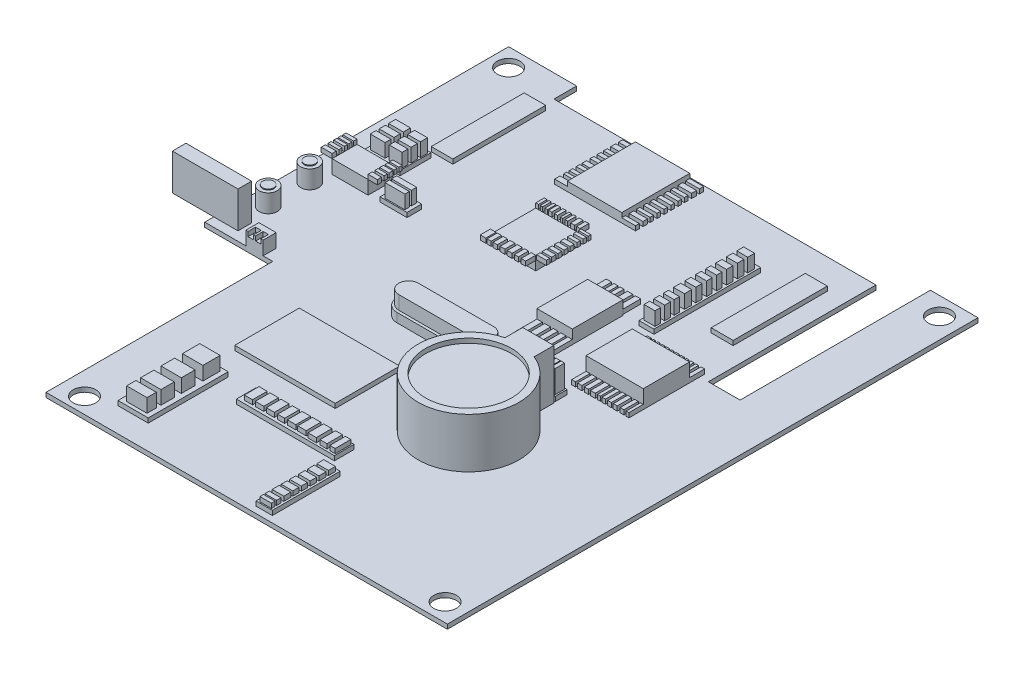
from build123d import *

# Parameters (mm, degrees)
BOSS_EXTRUDE1_DEPTH     = 1
SKETCH29_R              = 2.5
CUT_EXTRUDE1_DEPTH      = 1
SKETCH30_R              = 9.474583062
BOSS_EXTRUDE2_DEPTH     = 10
SKETCH32_R              = 11.129481628
SKETCH32_R_2            = 9.474583062
BOSS_EXTRUDE5_DEPTH     = 11
SKETCH33_W              = 6.859282088
SKETCH33_H              = 4.336444126
BOSS_EXTRUDE6_DEPTH     = 11
SKETCH94_W              = 6.467351118
SKETCH94_H              = 2.610316415
BOSS_EXTRUDE70_DEPTH    = 1
SKETCH95_W              = 0.898636231
SKETCH95_H              = 2.146154762
SKETCH95_W_2            = 0.803486512
SKETCH95_W_3            = 0.771769939
SKETCH95_W_4            = 0.78234213
SKETCH95_W_5            = 0.89863623
BOSS_EXTRUDE71_DEPTH    = 5
SKETCH96_W              = 12.624398434
SKETCH96_H              = 10.212996486
SKETCH96_W_2            = 7.801594538
SKETCH96_H_2            = 11.135003114
BOSS_EXTRUDE72_DEPTH    = 1
SKETCH97_W              = 0.854933858
SKETCH97_H              = 3.195934529
SKETCH97_W_2            = 0.973382942
SKETCH97_W_3            = 0.928109316
SKETCH97_W_4            = 1.063930191
SKETCH97_W_5            = 0.635991976
SKETCH97_W_6            = 0.769651627
SKETCH97_W_7            = 0.814925253
SKETCH97_W_8            = 0.882835691
SKETCH97_W_9            = 0.837562066
SKETCH97_W_10           = 0.60988367
SKETCH97_H_2            = 3.281548827
SKETCH97_W_11           = 0.486691471
SKETCH97_W_12           = 0.520646689
SKETCH97_W_13           = 0.689780349
SKETCH97_W_14           = 0.777801053
SKETCH97_W_15           = 0.598512769
SKETCH97_W_16           = 0.767490405
SKETCH97_W_17           = 0.67295067
SKETCH97_W_18           = 0.564415835
SKETCH97_W_19           = 0.651586297
SKETCH97_W_20           = 0.589205462
SKETCH97_W_21           = 0.803776824
BOSS_EXTRUDE73_DEPTH    = 1
SKETCH98_W              = 12.624398434
SKETCH98_H              = 10.197037506
BOSS_EXTRUDE74_DEPTH    = 3
SKETCH99_W              = 1.171777811
SKETCH99_H              = 4.8472176
SKETCH99_W_2            = 1.302225945
SKETCH99_W_3            = 1.035102674
SKETCH99_W_4            = 1.135273901
SKETCH99_W_5            = 0.986837632
SKETCH99_H_2            = 4.152195819
SKETCH99_W_6            = 0.901541038
SKETCH99_W_7            = 0.892546971
SKETCH99_W_8            = 1.202054718
SKETCH99_W_9            = 1.168664309
BOSS_EXTRUDE76_DEPTH    = 1
SKETCH100_W             = 7.801594538
SKETCH100_H             = 11.174835623
BOSS_EXTRUDE77_DEPTH    = 3
SKETCH101_W             = 4.843414572
SKETCH101_H             = 20.757491024
SKETCH101_W_2           = 3.286602746
SKETCH101_H_2           = 23.525156494
BOSS_EXTRUDE78_DEPTH    = 1
SKETCH102_W             = 2.415516683
SKETCH102_H             = 1.519437913
SKETCH102_H_2           = 1.44151802
SKETCH102_H_3           = 1.402558073
SKETCH102_H_4           = 1.168798395
SKETCH102_H_5           = 1.246718288
SKETCH102_H_6           = 1.363598127
SKETCH102_H_7           = 1.597357806
SKETCH102_H_8           = 1.168798394
SKETCH102_H_9           = 1.285678234
BOSS_EXTRUDE79_DEPTH    = 3
BOSS_EXTRUDE81_DEPTH    = 2
BOSS_EXTRUDE82_DEPTH    = 3
SKETCH109_W             = 22.146512199
SKETCH109_H             = 14.224182632
BOSS_EXTRUDE83_DEPTH    = 1
SKETCH110_W             = 6.661958954
SKETCH110_H             = 17.645188581
SKETCH110_W_2           = 21.606353365
SKETCH110_H_2           = 4.321270673
SKETCH110_W_3           = 3.601058894
SKETCH110_H_3           = 14.944394411
BOSS_EXTRUDE84_DEPTH    = 1
SKETCH111_W             = 4.495051817
SKETCH111_H             = 3.811022193
SKETCH111_H_2           = 3.029274051
SKETCH111_H_3           = 2.931555533
SKETCH111_H_4           = 2.052088873
BOSS_EXTRUDE85_DEPTH    = 3
SKETCH112_W             = 1.800095307
SKETCH112_H             = 3.236858559
SKETCH112_W_2           = 1.884972771
SKETCH112_W_3           = 1.772435211
SKETCH112_W_4           = 1.548527582
SKETCH112_W_5           = 1.856145182
SKETCH112_W_6           = 1.855853309
SKETCH112_W_7           = 1.827317594
SKETCH112_H_2           = 3.432631011
SKETCH112_W_8           = 1.548381646
SKETCH112_W_9           = 1.185151979
SKETCH112_W_10          = 2.560532791
SKETCH112_H_3           = 1.542958829
SKETCH112_H_4           = 1.543391648
SKETCH112_H_5           = 1.403004622
SKETCH112_H_6           = 1.348494525
SKETCH112_H_7           = 1.321023067
SKETCH112_H_8           = 1.54209319
SKETCH112_H_9           = 0.961730017
SKETCH112_H_10          = 0.794737171
BOSS_EXTRUDE86_DEPTH    = 1
SKETCH113_W             = 10
SKETCH113_H             = 10
SKETCH113_W_2           = 12
SKETCH113_H_2           = 15
BOSS_EXTRUDE87_DEPTH    = 2
SKETCH114_W             = 3.027436152
SKETCH114_H             = 0.924530577
SKETCH114_H_2           = 1.106308727
SKETCH114_H_3           = 0.804588165
SKETCH114_H_4           = 0.838112671
SKETCH114_H_5           = 0.838112672
SKETCH114_H_6           = 0.771063658
SKETCH114_H_7           = 1.005735206
SKETCH114_H_8           = 0.832239043
SKETCH114_W_2           = 2.793868574
SKETCH114_H_9           = 1.039259713
SKETCH114_H_10          = 0.670490137
SKETCH114_H_11          = 1.201008619
BOSS_EXTRUDE90_DEPTH    = 1
SKETCH115_W             = 1.218252667
SKETCH115_H             = 2.2340069
BOSS_EXTRUDE92_DEPTH    = 1
SKETCH115_W_2           = 0.904538566
BOSS_EXTRUDE92_2_DEPTH  = 1
SKETCH115_W_3           = 0.933717229
BOSS_EXTRUDE92_3_DEPTH  = 1
SKETCH115_W_4           = 1.050431882
BOSS_EXTRUDE92_4_DEPTH  = 1
SKETCH115_W_5           = 1.079610546
BOSS_EXTRUDE92_5_DEPTH  = 1
SKETCH115_W_6           = 0.875359903
BOSS_EXTRUDE92_6_DEPTH  = 1
SKETCH115_W_7           = 0.991044204
BOSS_EXTRUDE92_7_DEPTH  = 1
SKETCH115_W_8           = 2.132919208
SKETCH115_H_2           = 0.769606673
BOSS_EXTRUDE92_8_DEPTH  = 1
SKETCH115_H_3           = 0.945593409
BOSS_EXTRUDE92_9_DEPTH  = 1
SKETCH115_H_4           = 0.857604907
BOSS_EXTRUDE92_10_DEPTH = 1
SKETCH115_H_5           = 0.890627016
BOSS_EXTRUDE92_11_DEPTH = 1
SKETCH115_H_6           = 0.923595473
BOSS_EXTRUDE92_12_DEPTH = 1
SKETCH115_H_7           = 0.725614044
BOSS_EXTRUDE92_13_DEPTH = 1
SKETCH115_H_8           = 0.725623774
BOSS_EXTRUDE92_14_DEPTH = 1
SKETCH115_H_9           = 0.589147012
BOSS_EXTRUDE92_15_DEPTH = 1
SKETCH115_W_9           = 0.791437707
SKETCH115_H_10          = 1.896778749
BOSS_EXTRUDE92_16_DEPTH = 1
SKETCH115_W_10          = 0.902152651
BOSS_EXTRUDE92_17_DEPTH = 1
SKETCH115_W_11          = 0.61284124
BOSS_EXTRUDE92_18_DEPTH = 1
SKETCH115_W_12          = 0.525215942
BOSS_EXTRUDE92_19_DEPTH = 1
SKETCH115_W_13          = 0.704131469
BOSS_EXTRUDE92_20_DEPTH = 1
SKETCH115_W_14          = 0.706624959
BOSS_EXTRUDE92_21_DEPTH = 1
SKETCH115_W_15          = 0.572005981
BOSS_EXTRUDE92_22_DEPTH = 1
SKETCH115_W_16          = 0.510666695
BOSS_EXTRUDE92_23_DEPTH = 1
SKETCH115_W_17          = 0.603378895
BOSS_EXTRUDE92_24_DEPTH = 1
SKETCH116_W             = 4.749694189
SKETCH116_H             = 20.485451176
BOSS_EXTRUDE93_DEPTH    = 1
SKETCH117_W             = 7.945632429
SKETCH117_H             = 6.823502315
BOSS_EXTRUDE94_DEPTH    = 1
SKETCH118_W             = 3.270069498
SKETCH118_H             = 1.558773398
SKETCH118_W_2           = 2.842213247
SKETCH118_H_2           = 1.405995231
SKETCH118_H_3           = 1.283794323
BOSS_EXTRUDE95_DEPTH    = 3
SKETCH119_W             = 7.939308206
SKETCH119_H             = 5.475326854
BOSS_EXTRUDE96_DEPTH    = 3
SKETCH120_W             = 2.046149279
SKETCH120_H             = 0.734786807
BOSS_EXTRUDE97_DEPTH    = 1
SKETCH120_H_2           = 0.69351132
BOSS_EXTRUDE97_2_DEPTH  = 1
SKETCH120_H_3           = 0.842069262
BOSS_EXTRUDE97_3_DEPTH  = 1
SKETCH120_H_4           = 0.718287404
BOSS_EXTRUDE97_4_DEPTH  = 1
SKETCH120_H_5           = 0.928140606
BOSS_EXTRUDE97_5_DEPTH  = 1
SKETCH120_W_2           = 2.395983096
BOSS_EXTRUDE97_6_DEPTH  = 1
BOSS_EXTRUDE97_7_DEPTH  = 1
SKETCH120_H_6           = 0.666256695
BOSS_EXTRUDE97_8_DEPTH  = 1
BOSS_EXTRUDE97_9_DEPTH  = 1
BOSS_EXTRUDE97_10_DEPTH = 1
SKETCH121_W             = 5.943186366
SKETCH121_H             = 3.194636387
BOSS_EXTRUDE98_DEPTH    = 1
SKETCH122_W             = 4.383064798
SKETCH122_H             = 1.164264213
SKETCH122_H_2           = 0.990955742
BOSS_EXTRUDE99_DEPTH    = 3
SKETCH123_R             = 2
BOSS_EXTRUDE100_DEPTH   = 4
SKETCH125_R             = 1.241746015
SKETCH125_R_2           = 1.24572754
BOSS_EXTRUDE104_DEPTH   = 4.2
SKETCH126_W             = 3.798066901
SKETCH126_H             = 2.877820421
BOSS_EXTRUDE106_DEPTH   = 3
SKETCH128_W             = 1.251148543
SKETCH128_H             = 1.660086607
SKETCH128_W_2           = 1.13826296
CUT_EXTRUDE20_DEPTH     = 1
BOSS_EXTRUDE108_DEPTH   = 8
SKETCH131_W             = 5
SKETCH131_H             = 2
CUT_EXTRUDE22_DEPTH     = 1
SKETCH132_W             = 1.433328205
SKETCH132_H             = 7.5
CUT_EXTRUDE23_DEPTH     = 8
SKETCH133_W             = 1.5
SKETCH133_H             = 117
CUT_EXTRUDE24_DEPTH     = 2


with BuildPart() as part:
    # Sketch1 → Boss-Extrude1 (new body)
    with BuildSketch(Plane(origin=(0, 0, 0), x_dir=(1, 0, 0), z_dir=(0, 1, 0))):
        Polygon((93, 0), (105, 0), (105, -117), (15, -117), (15, -67), (0, -67), (0, 0), (15, 0), (15, -5), (86, -5), (86, -41.962014215), (93, -41.962014215), align=None)
    extrude(amount=BOSS_EXTRUDE1_DEPTH)

    # Sketch29 → Cut-Extrude1 (cut)
    with BuildSketch(Plane(origin=(0, 1, 0), x_dir=(1, 0, 0), z_dir=(0, 1, 0))):
        with Locations((99, -4)):
            Circle(SKETCH29_R)
        with Locations((4, -4)):
            Circle(SKETCH29_R)
        with Locations((20, -113.5)):
            Circle(SKETCH29_R)
        with Locations((99, -113)):
            Circle(SKETCH29_R)
    extrude(amount=-CUT_EXTRUDE1_DEPTH, mode=Mode.SUBTRACT)

    # Sketch30 → Boss-Extrude2 (add)
    with BuildSketch(Plane(origin=(0, 1, 0), x_dir=(1, 0, 0), z_dir=(0, 1, 0))):
        with Locations((68.930428836, -77.750419339)):
            Circle(SKETCH30_R)
    extrude(amount=BOSS_EXTRUDE2_DEPTH)

    # Sketch32 → Boss-Extrude5 (add)
    with BuildSketch(Plane(origin=(0, 1, 0), x_dir=(1, 0, 0), z_dir=(0, 1, 0))):
        with Locations((68.930428836, -77.750419339)):
            Circle(SKETCH32_R)
        with Locations((68.930428836, -77.750419339)):
            Circle(SKETCH32_R_2, mode=Mode.SUBTRACT)
    extrude(amount=BOSS_EXTRUDE5_DEPTH)

    # Sketch33 → Boss-Extrude6 (add)
    with BuildSketch(Plane(origin=(0, 1, 0), x_dir=(1, 0, 0), z_dir=(0, 1, 0))):
        with Locations((69.603565091, -65.236542161)):
            Rectangle(SKETCH33_W, SKETCH33_H)
    extrude(amount=BOSS_EXTRUDE6_DEPTH)

    # Sketch94 → Boss-Extrude70 (add)
    with BuildSketch(Plane(origin=(0, 1, 0), x_dir=(1, 0, 0), z_dir=(0, 1, 0))):
        with Locations((69.673344387, -61.312235302)):
            Rectangle(SKETCH94_W, SKETCH94_H)
    extrude(amount=BOSS_EXTRUDE70_DEPTH)

    # Sketch95 → Boss-Extrude71 (add)
    with BuildSketch(Plane(origin=(0, 2, 0), x_dir=(1, 0, 0), z_dir=(0, 1, 0))):
        with Locations((67.15008351, -61.310670018)):
            Rectangle(SKETCH95_W, SKETCH95_H)
        with Locations((68.212588701, -61.310670018)):
            Rectangle(SKETCH95_W_2, SKETCH95_H)
        with Locations((69.179944173, -61.310670018)):
            Rectangle(SKETCH95_W_3, SKETCH95_H)
        with Locations((70.094438689, -61.310670018)):
            Rectangle(SKETCH95_W_4, SKETCH95_H)
        with Locations((71.178088261, -61.310670018)):
            Rectangle(SKETCH95_W_5, SKETCH95_H)
        with Locations((72.203590783, -61.310670018)):
            Rectangle(SKETCH95_W_3, SKETCH95_H)
    extrude(amount=BOSS_EXTRUDE71_DEPTH)

    # Sketch96 → Boss-Extrude72 (add)
    with BuildSketch(Plane(origin=(0, 1, 0), x_dir=(1, 0, 0), z_dir=(0, 1, 0))):
        with Locations((77.833652458, -49.309656676)):
            Rectangle(SKETCH96_W, SKETCH96_H)
        with Locations((60.031832194, -44.309543813)):
            Rectangle(SKETCH96_W_2, SKETCH96_H_2)
    extrude(amount=BOSS_EXTRUDE72_DEPTH)

    # Sketch97 → Boss-Extrude73 (add)
    with BuildSketch(Plane(origin=(0, 1, 0), x_dir=(1, 0, 0), z_dir=(0, 1, 0))):
        with Locations((71.94892017, -56.014122184)):
            Rectangle(SKETCH97_W, SKETCH97_H)
        with Locations((73.292810312, -56.014122184)):
            Rectangle(SKETCH97_W_2, SKETCH97_H)
        with Locations((74.76420313, -56.014122184)):
            Rectangle(SKETCH97_W_3, SKETCH97_H)
        with Locations((76.190322323, -56.014122184)):
            Rectangle(SKETCH97_W_4, SKETCH97_H)
        with Locations((77.51565647, -56.014122184)):
            Rectangle(SKETCH97_W_5, SKETCH97_H)
        with Locations((78.601142863, -56.014122184)):
            Rectangle(SKETCH97_W_6, SKETCH97_H)
        with Locations((79.868804368, -56.014122184)):
            Rectangle(SKETCH97_W_7, SKETCH97_H)
        with Locations((81.125147466, -56.014122184)):
            Rectangle(SKETCH97_W_8, SKETCH97_H)
        with Locations((82.619177096, -56.014122184)):
            Rectangle(SKETCH97_W_9, SKETCH97_H)
        with Locations((83.84090984, -56.014122184)):
            Rectangle(SKETCH97_W_10, SKETCH97_H)
        with Locations((71.94892017, -42.56238402)):
            Rectangle(SKETCH97_W, SKETCH97_H_2)
        with Locations((73.049464577, -42.56238402)):
            Rectangle(SKETCH97_W_11, SKETCH97_H_2)
        with Locations((74.039825127, -42.56238402)):
            Rectangle(SKETCH97_W_12, SKETCH97_H_2)
        with Locations((75.109093304, -42.56238402)):
            Rectangle(SKETCH97_W_13, SKETCH97_H_2)
        with Locations((76.047257754, -42.56238402)):
            Rectangle(SKETCH97_W_14, SKETCH97_H_2)
        with Locations((77.119076697, -42.56238402)):
            Rectangle(SKETCH97_W_15, SKETCH97_H_2)
        with Locations((78.217397661, -42.56238402)):
            Rectangle(SKETCH97_W_16, SKETCH97_H_2)
        with Locations((79.322444011, -42.56238402)):
            Rectangle(SKETCH97_W_17, SKETCH97_H_2)
        with Locations((80.401521703, -42.56238402)):
            Rectangle(SKETCH97_W_18, SKETCH97_H_2)
        with Locations((81.450940614, -42.56238402)):
            Rectangle(SKETCH97_W_19, SKETCH97_H_2)
        with Locations((82.494998794, -42.56238402)):
            Rectangle(SKETCH97_W_20, SKETCH97_H_2)
        with Locations((83.743963263, -42.56238402)):
            Rectangle(SKETCH97_W_21, SKETCH97_H_2)
    extrude(amount=BOSS_EXTRUDE73_DEPTH)

    # Sketch98 → Boss-Extrude74 (add)
    with BuildSketch(Plane(origin=(0, 2, 0), x_dir=(1, 0, 0), z_dir=(0, 1, 0))):
        with Locations((77.833652458, -49.347219086)):
            Rectangle(SKETCH98_W, SKETCH98_H)
    extrude(amount=BOSS_EXTRUDE74_DEPTH)

    # Sketch99 → Boss-Extrude76 (add)
    with BuildSketch(Plane(origin=(0, 2, 0), x_dir=(1, 0, 0), z_dir=(0, 1, 0))):
        with Locations((56.716923831, -52.30065417)):
            Rectangle(SKETCH99_W, SKETCH99_H)
        with Locations((58.48817225, -52.30065417)):
            Rectangle(SKETCH99_W_2, SKETCH99_H)
        with Locations((60.257863919, -52.30065417)):
            Rectangle(SKETCH99_W_3, SKETCH99_H)
        with Locations((61.977469975, -52.30065417)):
            Rectangle(SKETCH99_W_4, SKETCH99_H)
        with Locations((63.439210647, -52.30065417)):
            Rectangle(SKETCH99_W_5, SKETCH99_H)
        with Locations((56.716923831, -36.665944347)):
            Rectangle(SKETCH99_W, SKETCH99_H_2)
        with Locations((58.287829797, -36.665944347)):
            Rectangle(SKETCH99_W_6, SKETCH99_H_2)
        with Locations((59.585558709, -36.665944347)):
            Rectangle(SKETCH99_W_7, SKETCH99_H_2)
        with Locations((61.376442615, -36.665944347)):
            Rectangle(SKETCH99_W_8, SKETCH99_H_2)
        with Locations((63.12943908, -36.665944347)):
            Rectangle(SKETCH99_W_9, SKETCH99_H_2)
    extrude(amount=-BOSS_EXTRUDE76_DEPTH)

    # Sketch100 → Boss-Extrude77 (add)
    with BuildSketch(Plane(origin=(0, 1, 0), x_dir=(1, 0, 0), z_dir=(0, 1, 0))):
        with Locations((60.031832194, -44.291023669)):
            Rectangle(SKETCH100_W, SKETCH100_H)
    extrude(amount=BOSS_EXTRUDE77_DEPTH)

    # Sketch101 → Boss-Extrude78 (add)
    with BuildSketch(Plane(origin=(0, 1, 0), x_dir=(1, 0, 0), z_dir=(0, 1, 0))):
        with Locations((79.419837663, -21.951915179)):
            Rectangle(SKETCH101_W, SKETCH101_H)
        with Locations((69.300560789, -27.141287935)):
            Rectangle(SKETCH101_W_2, SKETCH101_H_2)
    extrude(amount=BOSS_EXTRUDE78_DEPTH)

    # Sketch102 → Boss-Extrude79 (add)
    with BuildSketch(Plane(origin=(0, 2, 0), x_dir=(1, 0, 0), z_dir=(0, 1, 0))):
        with Locations((69.347419953, -17.072650481)):
            Rectangle(SKETCH102_W, SKETCH102_H)
        with Locations((69.347419953, -19.410247271)):
            Rectangle(SKETCH102_W, SKETCH102_H_2)
        with Locations((69.347419953, -21.806283981)):
            Rectangle(SKETCH102_W, SKETCH102_H_3)
        with Locations((69.347419953, -24.104920824)):
            Rectangle(SKETCH102_W, SKETCH102_H_4)
        with Locations((69.347419953, -26.286677827)):
            Rectangle(SKETCH102_W, SKETCH102_H_5)
        with Locations((69.347419953, -28.604794644)):
            Rectangle(SKETCH102_W, SKETCH102_H_6)
        with Locations((69.347419953, -30.98135138)):
            Rectangle(SKETCH102_W, SKETCH102_H_7)
        with Locations((69.347419953, -33.455307982)):
            Rectangle(SKETCH102_W, SKETCH102_H_8)
        with Locations((69.347419953, -35.500705173)):
            Rectangle(SKETCH102_W, SKETCH102_H_9)
        with Locations((69.347419953, -37.662982203)):
            Rectangle(SKETCH102_W, SKETCH102_H_5)
    extrude(amount=BOSS_EXTRUDE79_DEPTH)

    # Sketch107 → Boss-Extrude81 (add)
    with BuildSketch(Plane(origin=(0, 1, 0), x_dir=(1, 0, 0), z_dir=(0, 1, 0))):
        with BuildLine():
            Line((56.64463267, -65.03568186), (40.397457427, -65.03568186))
            ThreePointArc((40.397457427, -65.03568186), (37.630728309, -62.268952742), (40.397457427, -59.502223624))
            Line((40.397457427, -59.502223624), (56.64463267, -59.502223624))
            ThreePointArc((56.64463267, -59.502223624), (59.411361788, -62.268952742), (56.64463267, -65.03568186))
        make_face()
    extrude(amount=BOSS_EXTRUDE81_DEPTH)

    # Sketch108 → Boss-Extrude82 (add)
    with BuildSketch(Plane(origin=(0, 3, 0), x_dir=(1, 0, 0), z_dir=(0, 1, 0))):
        with BuildLine():
            Line((40.217457427, -60.102223624), (56.82463267, -60.102223624))
            ThreePointArc((56.82463267, -60.102223624), (58.991361788, -62.268952742), (56.82463267, -64.43568186))
            Line((56.82463267, -64.43568186), (40.217457427, -64.43568186))
            ThreePointArc((40.217457427, -64.43568186), (38.050728309, -62.268952742), (40.217457427, -60.102223624))
        make_face()
    extrude(amount=BOSS_EXTRUDE82_DEPTH)

    # Sketch109 → Boss-Extrude83 (add)
    with BuildSketch(Plane(origin=(0, 1, 0), x_dir=(1, 0, 0), z_dir=(0, 1, 0))):
        with Locations((38.906002675, -81.096644561)):
            Rectangle(SKETCH109_W, SKETCH109_H)
    extrude(amount=BOSS_EXTRUDE83_DEPTH)

    # Sketch110 → Boss-Extrude84 (add)
    with BuildSketch(Plane(origin=(0, 1, 0), x_dir=(1, 0, 0), z_dir=(0, 1, 0))):
        with Locations((28.823037771, -102.793024398)):
            Rectangle(SKETCH110_W, SKETCH110_H)
        with Locations((49.078994051, -96.131065444)):
            Rectangle(SKETCH110_W_2, SKETCH110_H_2)
        with Locations((61.68270018, -108.104586267)):
            Rectangle(SKETCH110_W_3, SKETCH110_H_3)
    extrude(amount=BOSS_EXTRUDE84_DEPTH)

    # Sketch111 → Boss-Extrude85 (add)
    with BuildSketch(Plane(origin=(0, 2, 0), x_dir=(1, 0, 0), z_dir=(0, 1, 0))):
        with Locations((28.896826148, -96.653098231)):
            Rectangle(SKETCH111_W, SKETCH111_H)
        with Locations((28.896826148, -101.783320414)):
            Rectangle(SKETCH111_W, SKETCH111_H_2)
        with Locations((28.896826148, -106.32723149)):
            Rectangle(SKETCH111_W, SKETCH111_H_3)
        with Locations((28.896826148, -109.845098131)):
            Rectangle(SKETCH111_W, SKETCH111_H_4)
    extrude(amount=BOSS_EXTRUDE85_DEPTH)

    # Sketch112 → Boss-Extrude86 (add)
    with BuildSketch(Plane(origin=(0, 2, 0), x_dir=(1, 0, 0), z_dir=(0, 1, 0))):
        with Locations((40.281437333, -96.023865857)):
            Rectangle(SKETCH112_W, SKETCH112_H)
        with Locations((42.727307624, -96.023865857)):
            Rectangle(SKETCH112_W_2, SKETCH112_H)
        with Locations((45.10300612, -96.023865857)):
            Rectangle(SKETCH112_W_3, SKETCH112_H)
        with Locations((47.479507266, -96.023865857)):
            Rectangle(SKETCH112_W_4, SKETCH112_H)
        with Locations((49.785033965, -96.023865857)):
            Rectangle(SKETCH112_W_5, SKETCH112_H)
        with Locations((52.077533267, -96.023865857)):
            Rectangle(SKETCH112_W_6, SKETCH112_H)
        with Locations((54.522892781, -96.121752084)):
            Rectangle(SKETCH112_W_7, SKETCH112_H_2)
        with Locations((57.011201805, -96.121752084)):
            Rectangle(SKETCH112_W_8, SKETCH112_H_2)
        with Locations((59.009840587, -96.121752084)):
            Rectangle(SKETCH112_W_9, SKETCH112_H_2)
        with Locations((61.759755, -102.002112552)):
            Rectangle(SKETCH112_W_10, SKETCH112_H_3)
        with Locations((61.759755, -104.078702629)):
            Rectangle(SKETCH112_W_10, SKETCH112_H_4)
        with Locations((61.759755, -106.086397652)):
            Rectangle(SKETCH112_W_10, SKETCH112_H_5)
        with Locations((61.759755, -108.080140537)):
            Rectangle(SKETCH112_W_10, SKETCH112_H_6)
        with Locations((61.759755, -109.948963402)):
            Rectangle(SKETCH112_W_10, SKETCH112_H_7)
        with Locations((61.759755, -111.831738405)):
            Rectangle(SKETCH112_W_10, SKETCH112_H_8)
        with Locations((61.759755, -113.728465548)):
            Rectangle(SKETCH112_W_10, SKETCH112_H_9)
        with Locations((61.759755, -114.919909498)):
            Rectangle(SKETCH112_W_10, SKETCH112_H_10)
    extrude(amount=BOSS_EXTRUDE86_DEPTH)

    # Sketch113 → Boss-Extrude87 (add)
    with BuildSketch(Plane(origin=(0, 1, 0), x_dir=(1, 0, 0), z_dir=(0, 1, 0))):
        with Locations((40.809770673, -34.824623025)):
            Rectangle(SKETCH113_W, SKETCH113_H)
        with Locations((40.14922423, -13.696457767)):
            Rectangle(SKETCH113_W_2, SKETCH113_H_2)
    extrude(amount=BOSS_EXTRUDE87_DEPTH)

    # Sketch114 → Boss-Extrude90 (add)
    with BuildSketch(Plane(origin=(0, 1, 0), x_dir=(1, 0, 0), z_dir=(0, 1, 0))):
        with Locations((47.662942306, -6.658723056)):
            Rectangle(SKETCH114_W, SKETCH114_H)
        with Locations((47.662942306, -8.278633997)):
            Rectangle(SKETCH114_W, SKETCH114_H_2)
        with Locations((47.662942306, -10.0051461)):
            Rectangle(SKETCH114_W, SKETCH114_H_3)
        with Locations((47.662942306, -11.429937643)):
            Rectangle(SKETCH114_W, SKETCH114_H_4)
        with Locations((47.662942306, -12.972064959)):
            Rectangle(SKETCH114_W, SKETCH114_H_5)
        with Locations((47.662942306, -14.547716782)):
            Rectangle(SKETCH114_W, SKETCH114_H_6)
        with Locations((47.662942306, -16.039557337)):
            Rectangle(SKETCH114_W, SKETCH114_H_3)
        with Locations((47.662942306, -17.598446907)):
            Rectangle(SKETCH114_W, SKETCH114_H_6)
        with Locations((47.662942306, -19.056762956)):
            Rectangle(SKETCH114_W, SKETCH114_H_7)
        with Locations((47.662942306, -20.780338246)):
            Rectangle(SKETCH114_W, SKETCH114_H_8)
        with Locations((32.752289943, -6.658723056)):
            Rectangle(SKETCH114_W_2, SKETCH114_H)
        with Locations((32.752289943, -8.278633997)):
            Rectangle(SKETCH114_W_2, SKETCH114_H_2)
        with Locations((32.752289943, -10.0051461)):
            Rectangle(SKETCH114_W_2, SKETCH114_H_3)
        with Locations((32.752289943, -11.429937643)):
            Rectangle(SKETCH114_W_2, SKETCH114_H_4)
        with Locations((32.752289943, -12.972064959)):
            Rectangle(SKETCH114_W_2, SKETCH114_H_5)
        with Locations((32.752289943, -14.68181481)):
            Rectangle(SKETCH114_W_2, SKETCH114_H_9)
        with Locations((32.752289943, -16.039557337)):
            Rectangle(SKETCH114_W_2, SKETCH114_H_3)
        with Locations((32.752289943, -17.598446907)):
            Rectangle(SKETCH114_W_2, SKETCH114_H_6)
        with Locations((32.752289943, -18.889140422)):
            Rectangle(SKETCH114_W_2, SKETCH114_H_10)
        with Locations((32.752289943, -20.595953458)):
            Rectangle(SKETCH114_W_2, SKETCH114_H_11)
    extrude(amount=BOSS_EXTRUDE90_DEPTH)

    # Sketch116 → Boss-Extrude93 (add)
    with BuildSketch(Plane(origin=(0, 1, 0), x_dir=(1, 0, 0), z_dir=(0, 1, 0))):
        with Locations((13.909798058, -18.346290919)):
            Rectangle(SKETCH116_W, SKETCH116_H)
    extrude(amount=BOSS_EXTRUDE93_DEPTH)

    # Sketch117 → Boss-Extrude94 (add)
    with BuildSketch(Plane(origin=(0, 1, 0), x_dir=(1, 0, 0), z_dir=(0, 1, 0))):
        with Locations((8.707442915, -33.194150479)):
            Rectangle(SKETCH117_W, SKETCH117_H)
    extrude(amount=BOSS_EXTRUDE94_DEPTH)

    # Sketch118 → Boss-Extrude95 (add)
    with BuildSketch(Plane(origin=(0, 2, 0), x_dir=(1, 0, 0), z_dir=(0, 1, 0))):
        with Locations((7.049688513, -31.106313162)):
            Rectangle(SKETCH118_W, SKETCH118_H)
        with Locations((11.022615664, -31.106313162)):
            Rectangle(SKETCH118_W_2, SKETCH118_H)
        with Locations((7.049688513, -33.26043305)):
            Rectangle(SKETCH118_W, SKETCH118_H_2)
        with Locations((11.022615664, -33.26043305)):
            Rectangle(SKETCH118_W_2, SKETCH118_H_2)
        with Locations((7.049688513, -35.277031866)):
            Rectangle(SKETCH118_W, SKETCH118_H_3)
        with Locations((11.022615664, -35.277031866)):
            Rectangle(SKETCH118_W_2, SKETCH118_H_3)
    extrude(amount=BOSS_EXTRUDE95_DEPTH)

    # Sketch119 → Boss-Extrude96 (add)
    with BuildSketch(Plane(origin=(0, 1, 0), x_dir=(1, 0, 0), z_dir=(0, 1, 0))):
        with Locations((8.897196738, -41.109755492)):
            Rectangle(SKETCH119_W, SKETCH119_H)
    extrude(amount=BOSS_EXTRUDE96_DEPTH)

    # Sketch121 → Boss-Extrude98 (add)
    with BuildSketch(Plane(origin=(0, 1, 0), x_dir=(1, 0, 0), z_dir=(0, 1, 0))):
        with Locations((18.469989514, -42.238881877)):
            Rectangle(SKETCH121_W, SKETCH121_H)
    extrude(amount=BOSS_EXTRUDE98_DEPTH)

    # Sketch122 → Boss-Extrude99 (add)
    with BuildSketch(Plane(origin=(0, 2, 0), x_dir=(1, 0, 0), z_dir=(0, 1, 0))):
        with Locations((18.510099975, -41.562302741)):
            Rectangle(SKETCH122_W, SKETCH122_H)
        with Locations((18.510099975, -43.084907563)):
            Rectangle(SKETCH122_W, SKETCH122_H_2)
    extrude(amount=BOSS_EXTRUDE99_DEPTH)

    # Sketch123 → Boss-Extrude100 (add)
    with BuildSketch(Plane(origin=(0, 1, 0), x_dir=(1, 0, 0), z_dir=(0, 1, 0))):
        with Locations((4, -47.847418919)):
            Circle(SKETCH123_R)
        with Locations((4, -57)):
            Circle(SKETCH123_R)
    extrude(amount=BOSS_EXTRUDE100_DEPTH)

    # Sketch125 → Boss-Extrude104 (add)
    with BuildSketch(Plane(origin=(0, 1, 0), x_dir=(1, 0, 0), z_dir=(0, 1, 0))):
        with Locations((4, -47.847418919)):
            Circle(SKETCH125_R)
        with Locations((4, -57)):
            Circle(SKETCH125_R_2)
    extrude(amount=BOSS_EXTRUDE104_DEPTH)

    # Sketch126 → Boss-Extrude106 (add)
    with BuildSketch(Plane(origin=(0, 1, 0), x_dir=(1, 0, 0), z_dir=(0, 1, 0))):
        with Locations((10.968471201, -65.56108979)):
            Rectangle(SKETCH126_W, SKETCH126_H)
    extrude(amount=BOSS_EXTRUDE106_DEPTH)

    # Sketch128 → Cut-Extrude20 (cut)
    with BuildSketch(Plane(origin=(0, 4, 0), x_dir=(1, 0, 0), z_dir=(0, 1, 0))):
        with Locations((10.180791352, -66.169956697)):
            Rectangle(SKETCH128_W, SKETCH128_H)
        with Locations((11.798818038, -66.169956697)):
            Rectangle(SKETCH128_W_2, SKETCH128_H)
    extrude(amount=-CUT_EXTRUDE20_DEPTH, mode=Mode.SUBTRACT)

    # Sketch129 → Boss-Extrude108 (add)
    with BuildSketch(Plane(origin=(0, 1, 0), x_dir=(1, 0, 0), z_dir=(0, 1, 0))):
        Polygon((-9.140572503, -65), (0, -65), (5.333141952, -65), (5.333141952, -62), (-9.140572503, -62), align=None)
    extrude(amount=BOSS_EXTRUDE108_DEPTH)

    # Sketch131 → Cut-Extrude22 (cut)
    with BuildSketch(Plane(origin=(0, 0, 62), x_dir=(-1, 0, 0), z_dir=(0, 0, -1))):
        with Locations((5.166858048, 3.5)):
            Rectangle(SKETCH131_W, SKETCH131_H)
        with Locations((5.166858048, 6.5)):
            Rectangle(SKETCH131_W, SKETCH131_H)
    extrude(amount=-CUT_EXTRUDE22_DEPTH, mode=Mode.SUBTRACT)

    # Sketch132 → Cut-Extrude23 (cut)
    with BuildSketch(Plane.ZY.offset(9.140572503)):
        with Locations((63.156609417, 5)):
            Rectangle(SKETCH132_W, SKETCH132_H)
    extrude(amount=-CUT_EXTRUDE23_DEPTH, mode=Mode.SUBTRACT)

    # Sketch133 → Cut-Extrude24 (cut)
    with BuildSketch(Plane(origin=(0, 1, 0), x_dir=(1, 0, 0), z_dir=(0, 1, 0))):
        with Locations((104.25, -58.5)):
            Rectangle(SKETCH133_W, SKETCH133_H)
    extrude(amount=-CUT_EXTRUDE24_DEPTH, mode=Mode.SUBTRACT)


with BuildPart() as body_2:
    # Sketch115 → Boss-Extrude92 (new body)
    with BuildSketch(Plane(origin=(0, 3, 0), x_dir=(1, 0, 0), z_dir=(0, 1, 0))):
        with Locations((36.418897007, -40.941626475)):
            Rectangle(SKETCH115_W, SKETCH115_H)
    extrude(amount=BOSS_EXTRUDE92_DEPTH)


with BuildPart() as body_3:
    # Sketch115 → Boss-Extrude92 2 (new body)
    with BuildSketch(Plane(origin=(0, 3, 0), x_dir=(1, 0, 0), z_dir=(0, 1, 0))):
        with Locations((37.772079257, -40.941626475)):
            Rectangle(SKETCH115_W_2, SKETCH115_H)
    extrude(amount=BOSS_EXTRUDE92_2_DEPTH)


with BuildPart() as body_4:
    # Sketch115 → Boss-Extrude92 3 (new body)
    with BuildSketch(Plane(origin=(0, 3, 0), x_dir=(1, 0, 0), z_dir=(0, 1, 0))):
        with Locations((39.099708441, -40.941626475)):
            Rectangle(SKETCH115_W_3, SKETCH115_H)
    extrude(amount=BOSS_EXTRUDE92_3_DEPTH)


with BuildPart() as body_5:
    # Sketch115 → Boss-Extrude92 4 (new body)
    with BuildSketch(Plane(origin=(0, 3, 0), x_dir=(1, 0, 0), z_dir=(0, 1, 0))):
        with Locations((40.704534929, -40.941626475)):
            Rectangle(SKETCH115_W_4, SKETCH115_H)
    extrude(amount=BOSS_EXTRUDE92_4_DEPTH)


with BuildPart() as body_6:
    # Sketch115 → Boss-Extrude92 5 (new body)
    with BuildSketch(Plane(origin=(0, 3, 0), x_dir=(1, 0, 0), z_dir=(0, 1, 0))):
        with Locations((42.294772085, -40.941626475)):
            Rectangle(SKETCH115_W_5, SKETCH115_H)
    extrude(amount=BOSS_EXTRUDE92_5_DEPTH)


with BuildPart() as body_7:
    # Sketch115 → Boss-Extrude92 6 (new body)
    with BuildSketch(Plane(origin=(0, 3, 0), x_dir=(1, 0, 0), z_dir=(0, 1, 0))):
        with Locations((43.768294587, -40.941626475)):
            Rectangle(SKETCH115_W_6, SKETCH115_H)
    extrude(amount=BOSS_EXTRUDE92_6_DEPTH)


with BuildPart() as body_8:
    # Sketch115 → Boss-Extrude92 7 (new body)
    with BuildSketch(Plane(origin=(0, 3, 0), x_dir=(1, 0, 0), z_dir=(0, 1, 0))):
        with Locations((45.314248571, -40.941626475)):
            Rectangle(SKETCH115_W_7, SKETCH115_H)
    extrude(amount=BOSS_EXTRUDE92_7_DEPTH)


with BuildPart() as body_9:
    # Sketch115 → Boss-Extrude92 8 (new body)
    with BuildSketch(Plane(origin=(0, 3, 0), x_dir=(1, 0, 0), z_dir=(0, 1, 0))):
        with Locations((46.876230277, -39.246079409)):
            Rectangle(SKETCH115_W_8, SKETCH115_H_2)
    extrude(amount=BOSS_EXTRUDE92_8_DEPTH)


with BuildPart() as body_10:
    # Sketch115 → Boss-Extrude92 9 (new body)
    with BuildSketch(Plane(origin=(0, 3, 0), x_dir=(1, 0, 0), z_dir=(0, 1, 0))):
        with Locations((46.876230277, -37.970200711)):
            Rectangle(SKETCH115_W_8, SKETCH115_H_3)
    extrude(amount=BOSS_EXTRUDE92_9_DEPTH)


with BuildPart() as body_11:
    # Sketch115 → Boss-Extrude92 10 (new body)
    with BuildSketch(Plane(origin=(0, 3, 0), x_dir=(1, 0, 0), z_dir=(0, 1, 0))):
        with Locations((46.876230277, -36.650322897)):
            Rectangle(SKETCH115_W_8, SKETCH115_H_4)
    extrude(amount=BOSS_EXTRUDE92_10_DEPTH)


with BuildPart() as body_12:
    # Sketch115 → Boss-Extrude92 11 (new body)
    with BuildSketch(Plane(origin=(0, 3, 0), x_dir=(1, 0, 0), z_dir=(0, 1, 0))):
        with Locations((46.876230277, -35.269936533)):
            Rectangle(SKETCH115_W_8, SKETCH115_H_5)
    extrude(amount=BOSS_EXTRUDE92_11_DEPTH)


with BuildPart() as body_13:
    # Sketch115 → Boss-Extrude92 12 (new body)
    with BuildSketch(Plane(origin=(0, 3, 0), x_dir=(1, 0, 0), z_dir=(0, 1, 0))):
        with Locations((46.876230277, -33.933572868)):
            Rectangle(SKETCH115_W_8, SKETCH115_H_6)
    extrude(amount=BOSS_EXTRUDE92_12_DEPTH)


with BuildPart() as body_14:
    # Sketch115 → Boss-Extrude92 13 (new body)
    with BuildSketch(Plane(origin=(0, 3, 0), x_dir=(1, 0, 0), z_dir=(0, 1, 0))):
        with Locations((46.876230277, -32.492708024)):
            Rectangle(SKETCH115_W_8, SKETCH115_H_7)
    extrude(amount=BOSS_EXTRUDE92_13_DEPTH)


with BuildPart() as body_15:
    # Sketch115 → Boss-Extrude92 14 (new body)
    with BuildSketch(Plane(origin=(0, 3, 0), x_dir=(1, 0, 0), z_dir=(0, 1, 0))):
        with Locations((46.876230277, -31.172833453)):
            Rectangle(SKETCH115_W_8, SKETCH115_H_8)
    extrude(amount=BOSS_EXTRUDE92_14_DEPTH)


with BuildPart() as body_16:
    # Sketch115 → Boss-Extrude92 15 (new body)
    with BuildSketch(Plane(origin=(0, 3, 0), x_dir=(1, 0, 0), z_dir=(0, 1, 0))):
        with Locations((46.876230277, -30.119196531)):
            Rectangle(SKETCH115_W_8, SKETCH115_H_9)
    extrude(amount=BOSS_EXTRUDE92_15_DEPTH)


with BuildPart() as body_17:
    # Sketch115 → Boss-Extrude92 16 (new body)
    with BuildSketch(Plane(origin=(0, 3, 0), x_dir=(1, 0, 0), z_dir=(0, 1, 0))):
        with Locations((45.214445323, -28.876233651)):
            Rectangle(SKETCH115_W_9, SKETCH115_H_10)
    extrude(amount=BOSS_EXTRUDE92_16_DEPTH)


with BuildPart() as body_18:
    # Sketch115 → Boss-Extrude92 17 (new body)
    with BuildSketch(Plane(origin=(0, 3, 0), x_dir=(1, 0, 0), z_dir=(0, 1, 0))):
        with Locations((43.926952009, -28.876233651)):
            Rectangle(SKETCH115_W_10, SKETCH115_H_10)
    extrude(amount=BOSS_EXTRUDE92_17_DEPTH)


with BuildPart() as body_19:
    # Sketch115 → Boss-Extrude92 18 (new body)
    with BuildSketch(Plane(origin=(0, 3, 0), x_dir=(1, 0, 0), z_dir=(0, 1, 0))):
        with Locations((42.528156738, -28.876233651)):
            Rectangle(SKETCH115_W_11, SKETCH115_H_10)
    extrude(amount=BOSS_EXTRUDE92_18_DEPTH)


with BuildPart() as body_20:
    # Sketch115 → Boss-Extrude92 19 (new body)
    with BuildSketch(Plane(origin=(0, 3, 0), x_dir=(1, 0, 0), z_dir=(0, 1, 0))):
        with Locations((41.492358841, -28.876233651)):
            Rectangle(SKETCH115_W_12, SKETCH115_H_10)
    extrude(amount=BOSS_EXTRUDE92_19_DEPTH)


with BuildPart() as body_21:
    # Sketch115 → Boss-Extrude92 20 (new body)
    with BuildSketch(Plane(origin=(0, 3, 0), x_dir=(1, 0, 0), z_dir=(0, 1, 0))):
        with Locations((40.263549745, -28.876233651)):
            Rectangle(SKETCH115_W_13, SKETCH115_H_10)
    extrude(amount=BOSS_EXTRUDE92_20_DEPTH)


with BuildPart() as body_22:
    # Sketch115 → Boss-Extrude92 21 (new body)
    with BuildSketch(Plane(origin=(0, 3, 0), x_dir=(1, 0, 0), z_dir=(0, 1, 0))):
        with Locations((38.986162307, -28.876233651)):
            Rectangle(SKETCH115_W_14, SKETCH115_H_10)
    extrude(amount=BOSS_EXTRUDE92_21_DEPTH)


with BuildPart() as body_23:
    # Sketch115 → Boss-Extrude92 22 (new body)
    with BuildSketch(Plane(origin=(0, 3, 0), x_dir=(1, 0, 0), z_dir=(0, 1, 0))):
        with Locations((38.1073104, -28.876233651)):
            Rectangle(SKETCH115_W_15, SKETCH115_H_10)
    extrude(amount=BOSS_EXTRUDE92_22_DEPTH)


with BuildPart() as body_24:
    # Sketch115 → Boss-Extrude92 23 (new body)
    with BuildSketch(Plane(origin=(0, 3, 0), x_dir=(1, 0, 0), z_dir=(0, 1, 0))):
        with Locations((37.064476627, -28.876233651)):
            Rectangle(SKETCH115_W_16, SKETCH115_H_10)
    extrude(amount=BOSS_EXTRUDE92_23_DEPTH)


with BuildPart() as body_25:
    # Sketch115 → Boss-Extrude92 24 (new body)
    with BuildSketch(Plane(origin=(0, 3, 0), x_dir=(1, 0, 0), z_dir=(0, 1, 0))):
        with Locations((36.11146012, -28.876233651)):
            Rectangle(SKETCH115_W_17, SKETCH115_H_10)
    extrude(amount=BOSS_EXTRUDE92_24_DEPTH)


with BuildPart() as body_26:
    # Sketch120 → Boss-Extrude97 (new body)
    with BuildSketch(Plane(origin=(0, 4, 0), x_dir=(1, 0, 0), z_dir=(0, 1, 0))):
        with Locations((13.889925481, -38.739485469)):
            Rectangle(SKETCH120_W, SKETCH120_H)
    extrude(amount=BOSS_EXTRUDE97_DEPTH)


with BuildPart() as body_27:
    # Sketch120 → Boss-Extrude97 2 (new body)
    with BuildSketch(Plane(origin=(0, 4, 0), x_dir=(1, 0, 0), z_dir=(0, 1, 0))):
        with Locations((13.889925481, -39.824699022)):
            Rectangle(SKETCH120_W, SKETCH120_H_2)
    extrude(amount=BOSS_EXTRUDE97_2_DEPTH)


with BuildPart() as body_28:
    # Sketch120 → Boss-Extrude97 3 (new body)
    with BuildSketch(Plane(origin=(0, 4, 0), x_dir=(1, 0, 0), z_dir=(0, 1, 0))):
        with Locations((13.889925481, -40.864533428)):
            Rectangle(SKETCH120_W, SKETCH120_H_3)
    extrude(amount=BOSS_EXTRUDE97_3_DEPTH)


with BuildPart() as body_29:
    # Sketch120 → Boss-Extrude97 4 (new body)
    with BuildSketch(Plane(origin=(0, 4, 0), x_dir=(1, 0, 0), z_dir=(0, 1, 0))):
        with Locations((13.889925481, -42.01576895)):
            Rectangle(SKETCH120_W, SKETCH120_H_4)
    extrude(amount=BOSS_EXTRUDE97_4_DEPTH)


with BuildPart() as body_30:
    # Sketch120 → Boss-Extrude97 5 (new body)
    with BuildSketch(Plane(origin=(0, 4, 0), x_dir=(1, 0, 0), z_dir=(0, 1, 0))):
        with Locations((13.889925481, -43.383348616)):
            Rectangle(SKETCH120_W, SKETCH120_H_5)
    extrude(amount=BOSS_EXTRUDE97_5_DEPTH)


with BuildPart() as body_31:
    # Sketch120 → Boss-Extrude97 6 (new body)
    with BuildSketch(Plane(origin=(0, 4, 0), x_dir=(1, 0, 0), z_dir=(0, 1, 0))):
        with Locations((3.729551087, -38.739485469)):
            Rectangle(SKETCH120_W_2, SKETCH120_H)
    extrude(amount=BOSS_EXTRUDE97_6_DEPTH)


with BuildPart() as body_32:
    # Sketch120 → Boss-Extrude97 7 (new body)
    with BuildSketch(Plane(origin=(0, 4, 0), x_dir=(1, 0, 0), z_dir=(0, 1, 0))):
        with Locations((3.729551087, -39.824699022)):
            Rectangle(SKETCH120_W_2, SKETCH120_H_2)
    extrude(amount=BOSS_EXTRUDE97_7_DEPTH)


with BuildPart() as body_33:
    # Sketch120 → Boss-Extrude97 8 (new body)
    with BuildSketch(Plane(origin=(0, 4, 0), x_dir=(1, 0, 0), z_dir=(0, 1, 0))):
        with Locations((3.729551087, -40.776627145)):
            Rectangle(SKETCH120_W_2, SKETCH120_H_6)
    extrude(amount=BOSS_EXTRUDE97_8_DEPTH)


with BuildPart() as body_34:
    # Sketch120 → Boss-Extrude97 9 (new body)
    with BuildSketch(Plane(origin=(0, 4, 0), x_dir=(1, 0, 0), z_dir=(0, 1, 0))):
        with Locations((3.729551087, -42.01576895)):
            Rectangle(SKETCH120_W_2, SKETCH120_H_4)
    extrude(amount=BOSS_EXTRUDE97_9_DEPTH)


with BuildPart() as body_35:
    # Sketch120 → Boss-Extrude97 10 (new body)
    with BuildSketch(Plane(origin=(0, 4, 0), x_dir=(1, 0, 0), z_dir=(0, 1, 0))):
        with Locations((3.729551087, -43.383348616)):
            Rectangle(SKETCH120_W_2, SKETCH120_H_5)
    extrude(amount=BOSS_EXTRUDE97_10_DEPTH)


solid = Compound([part.part, body_2.part, body_3.part, body_4.part, body_5.part, body_6.part, body_7.part, body_8.part, body_9.part, body_10.part, body_11.part, body_12.part, body_13.part, body_14.part, body_15.part, body_16.part, body_17.part, body_18.part, body_19.part, body_20.part, body_21.part, body_22.part, body_23.part, body_24.part, body_25.part, body_26.part, body_27.part, body_28.part, body_29.part, body_30.part, body_31.part, body_32.part, body_33.part, body_34.part, body_35.part])
